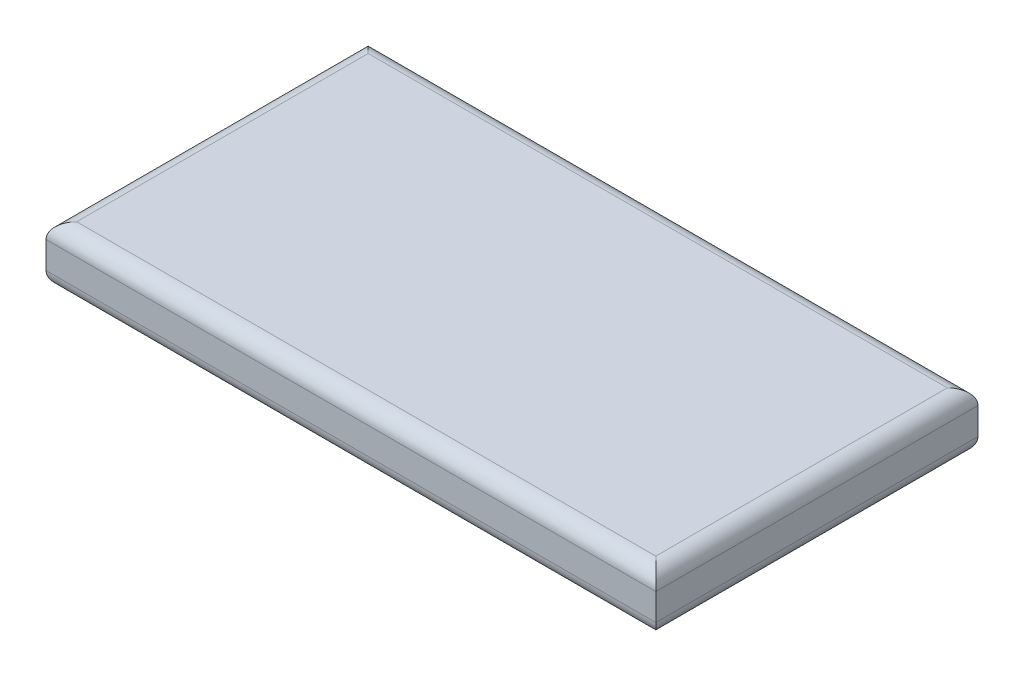
from build123d import *

# Parameters (mm, degrees)
SKETCH1_W           = 159
SKETCH1_H           = 84
BOSS_EXTRUDE1_DEPTH = 15
FILLET1_R           = 4


with BuildPart() as part:
    # Sketch1 → Boss-Extrude1 (new body)
    with BuildSketch(Plane(origin=(0, 0, 0), x_dir=(1, 0, 0), z_dir=(0, 1, 0))):
        Rectangle(SKETCH1_W, SKETCH1_H)
    extrude(amount=BOSS_EXTRUDE1_DEPTH)

    # Fillet1
    fillet1_edges = [part.edges().sort_by_distance(p)[0] for p in [
        (-79.5, 15, 0),
        (0, 15, 42),
        (79.5, 15, 0),
        (0, 0, 42),
        (-79.5, 0, 0),
        (0, 0, -42),
        (79.5, 0, 0),
        (0, 15, -42),
    ]]
    fillet(fillet1_edges, radius=FILLET1_R)


solid = part.part
